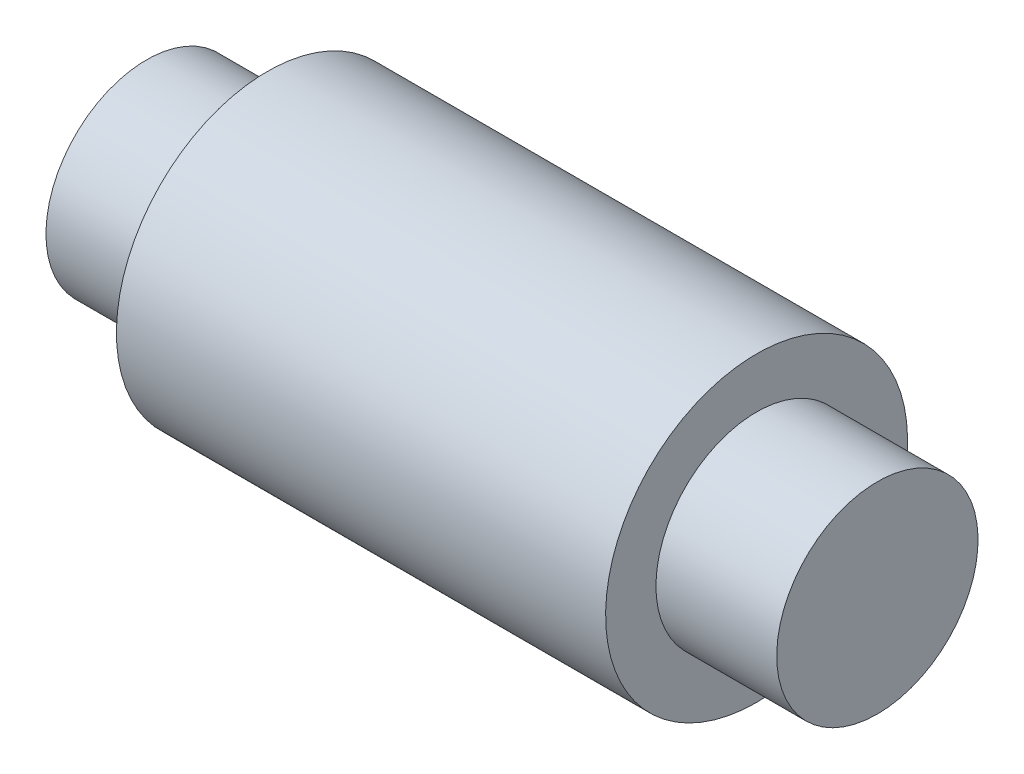
from build123d import *


with BuildPart() as part:
    # Sketch1 → Revolve1 (revolve)
    with BuildSketch(Plane.XY):
        Polygon((0, 0), (0, -10), (72.6, -10), (72.6, 0), (60.6, 0), (60.6, 5), (12, 5), (12, 0), align=None)
    revolve(axis=Axis((0, -10, 0), (1, 0, 0)))


solid = part.part
